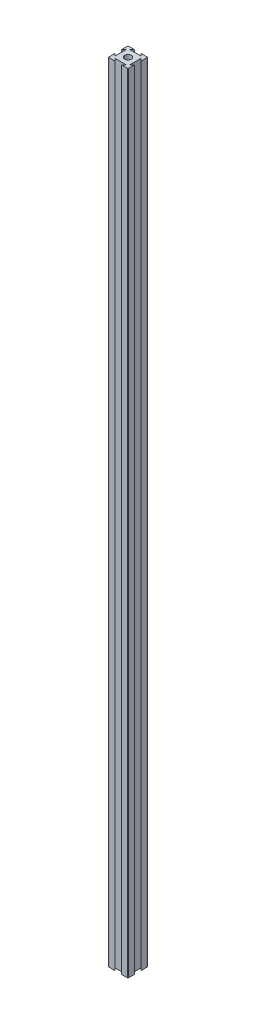
from build123d import *

# Parameters (mm, degrees)
SKETCH1_R           = 3.333333333
BOSS_EXTRUDE1_DEPTH = 800.1
FILLET4_R           = 0.508


with BuildPart() as part:
    # Sketch1 → Boss-Extrude1 (new body)
    with BuildSketch(Plane(origin=(0, 0, 0), x_dir=(1, 0, 0), z_dir=(0, 1, 0))):
        Polygon((4.285, 17.618333333), (6.666666667, 20), (0, 20), (0, 13.333333333), (2.381666667, 15.715), (2.381666667, 4.285), (0, 6.666666667), (0, 0), (6.666666667, 0), (4.285, 2.381666667), (15.715, 2.381666667), (13.333333333, 0), (20, 0), (20, 6.666666667), (17.618333333, 4.285), (17.618333333, 15.715), (20, 13.333333333), (20, 20), (13.333333333, 20), (15.715, 17.618333333), align=None)
        with Locations((10, 10)):
            Circle(SKETCH1_R, mode=Mode.SUBTRACT)
    extrude(amount=BOSS_EXTRUDE1_DEPTH)

    # Fillet4
    fillet4_edges = [part.edges().sort_by_distance(p)[0] for p in [
        (20, 400.05, 0),
        (0, 400.05, 0),
        (0, 400.05, -20),
        (20, 400.05, -20),
    ]]
    fillet(fillet4_edges, radius=FILLET4_R)


solid = part.part
